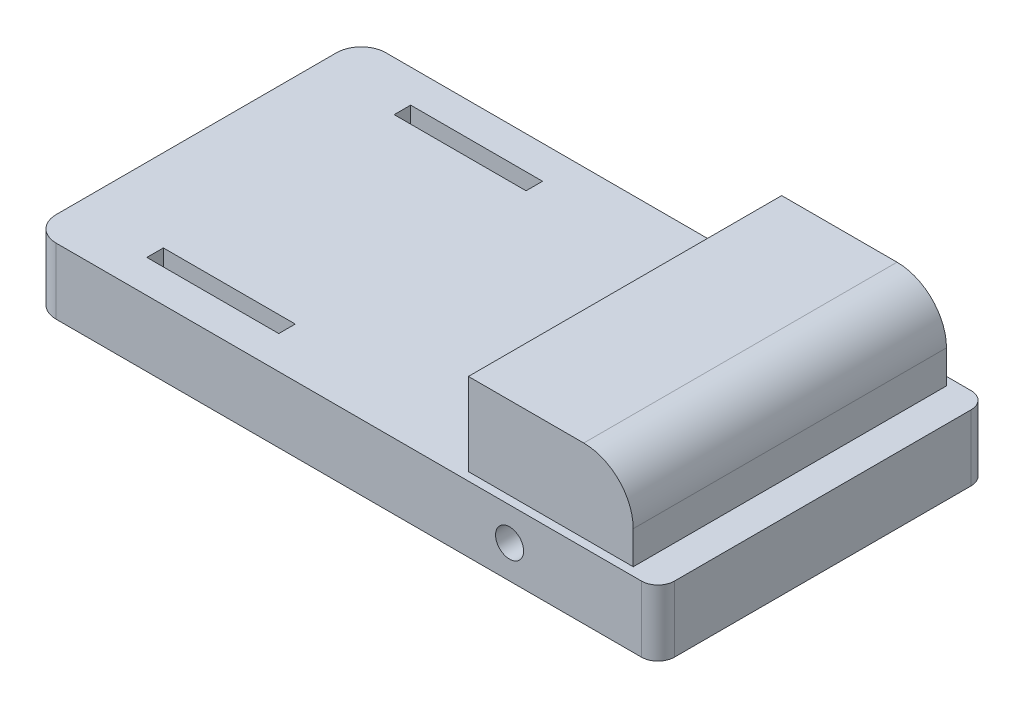
from build123d import *

# Parameters (mm, degrees)
SKETCH1_W           = 965.2
SKETCH1_H           = 508
BOSS_EXTRUDE1_DEPTH = 101.6
SKETCH2_R           = 21.59
CUT_EXTRUDE1_DEPTH  = 509
FILLET1_R           = 38.1
FILLET2_R           = 25.4
CUT_EXTRUDE2_REACH  = 103.6
SKETCH4_W           = 203.2
SKETCH4_H           = 25.4
SKETCH6_W           = 253.917216802
SKETCH6_H           = 482.6
BOSS_EXTRUDE3_DEPTH = 127
FILLET4_R           = 76.2
SKETCH7_W           = 457.2
SKETCH7_H           = 114.3
CUT_EXTRUDE4_DEPTH  = 179


with BuildPart() as part:
    # Sketch1 → Boss-Extrude1 (new body)
    with BuildSketch(Plane(origin=(0, 0, 0), x_dir=(1, 0, 0), z_dir=(0, 1, 0))):
        Rectangle(SKETCH1_W, SKETCH1_H)
    extrude(amount=BOSS_EXTRUDE1_DEPTH)

    # Sketch2 → Cut-Extrude1 (cut, through all)
    with BuildSketch(Plane.XY.offset(254)):
        with Locations((254, 50.8)):
            Circle(SKETCH2_R)
    extrude(amount=-CUT_EXTRUDE1_DEPTH, mode=Mode.SUBTRACT)

    # Fillet1
    fillet1_edges = [part.edges().sort_by_distance(p)[0] for p in [
        (-482.6, 50.8, -254),
        (-482.6, 50.8, 254),
    ]]
    fillet(fillet1_edges, radius=FILLET1_R)

    # Fillet2
    fillet2_edges = [part.edges().sort_by_distance(p)[0] for p in [
        (482.6, 50.8, -254),
        (482.6, 50.8, 254),
    ]]
    fillet(fillet2_edges, radius=FILLET2_R)

    # Sketch4 → Cut-Extrude2 (cut, up to next)
    with BuildSketch(Plane(origin=(0, 101.6, 0), x_dir=(1, 0, 0), z_dir=(0, 1, 0)), mode=Mode.PRIVATE) as cut_extrude2_sk1:
        with Locations((-254, -190.5)):
            Rectangle(SKETCH4_W, SKETCH4_H)
    cut_extrude2_tool1 = extrude(cut_extrude2_sk1.sketch, amount=-CUT_EXTRUDE2_REACH, mode=Mode.PRIVATE) & part.part
    add(cut_extrude2_tool1.solids().sort_by_distance((-254, 101.6, 190.5))[0], mode=Mode.SUBTRACT)
    # Sketch4 → Cut-Extrude2 (cut, up to next)
    with BuildSketch(Plane(origin=(0, 101.6, 0), x_dir=(1, 0, 0), z_dir=(0, 1, 0)), mode=Mode.PRIVATE) as cut_extrude2_sk2:
        with Locations((-254, 190.5)):
            Rectangle(SKETCH4_W, SKETCH4_H)
    cut_extrude2_tool2 = extrude(cut_extrude2_sk2.sketch, amount=-CUT_EXTRUDE2_REACH, mode=Mode.PRIVATE) & part.part
    add(cut_extrude2_tool2.solids().sort_by_distance((-254, 101.6, -190.5))[0], mode=Mode.SUBTRACT)

    # Sketch6 → Boss-Extrude3 (add)
    with BuildSketch(Plane(origin=(0, 101.6, 0), x_dir=(1, 0, 0), z_dir=(0, 1, 0))):
        with Locations((304.841391599, 0)):
            Rectangle(SKETCH6_W, SKETCH6_H)
    extrude(amount=BOSS_EXTRUDE3_DEPTH)

    # Fillet4
    fillet4_edges = [part.edges().sort_by_distance(p)[0] for p in [
        (431.8, 228.6, 0),
    ]]
    fillet(fillet4_edges, radius=FILLET4_R)

    # Sketch7 → Cut-Extrude4 (cut)
    with BuildSketch(Plane.ZY.offset(-177.882783198)):
        with Locations((0, 158.75)):
            Rectangle(SKETCH7_W, SKETCH7_H)
    extrude(amount=-CUT_EXTRUDE4_DEPTH, mode=Mode.SUBTRACT)


solid = part.part
